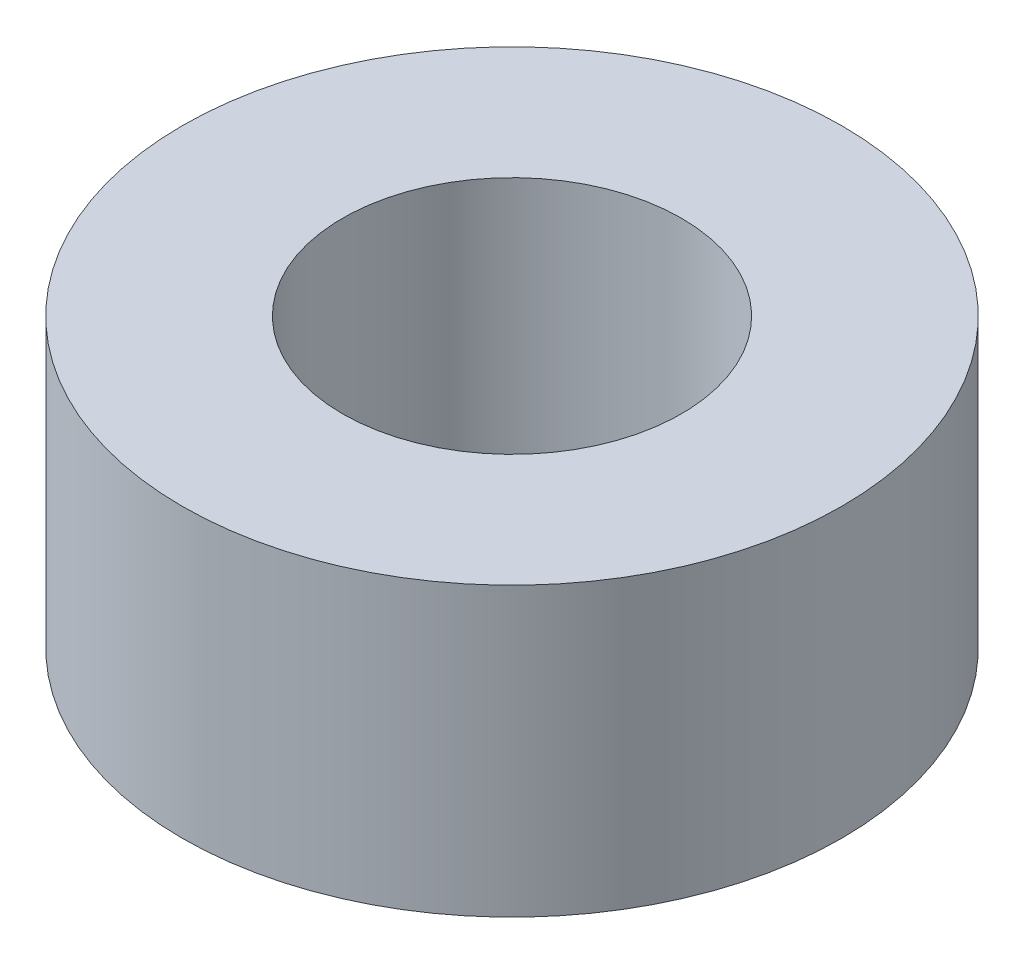
from build123d import *

# Parameters (mm, degrees)
SKETCH1_R           = 6.35
SKETCH1_R_2         = 3.2639
BOSS_EXTRUDE1_DEPTH = 5.5372


with BuildPart() as part:
    # Sketch1 → Boss-Extrude1 (new body)
    with BuildSketch(Plane(origin=(0, 0, 0), x_dir=(1, 0, 0), z_dir=(0, 1, 0))):
        Circle(SKETCH1_R)
        Circle(SKETCH1_R_2, mode=Mode.SUBTRACT)
    extrude(amount=BOSS_EXTRUDE1_DEPTH)


solid = part.part
